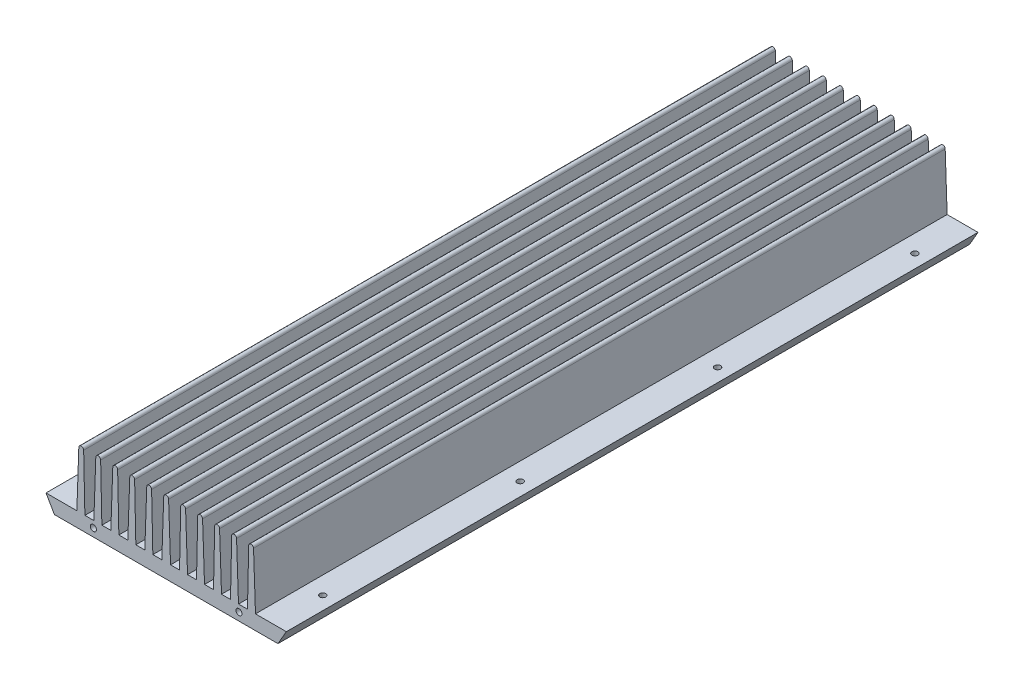
from build123d import *

# Parameters (mm, degrees)
RESSALTO_EXTRUS_O1_DEPTH   = 285
CORTE_EXTRUS_O1_DEPTH      = 309.048697449
CORTE_EXTRUS_O1_DEPTH_BACK = 309.048697449
CORTE_EXTRUS_O2_DEPTH      = 306.556550496
CORTE_EXTRUS_O2_DEPTH_BACK = 306.556550496
ESBO_O3_W                  = 25.376323639
ESBO_O3_H                  = 34.077714497
ESBO_O3_W_2                = 22.64317054
ESBO_O3_H_2                = 30.700240827
ESBO_O4_R                  = 1.25
CORTE_EXTRUS_O3_DEPTH      = 10
ESBO_O5_R                  = 1.25
CORTE_EXTRUS_O4_DEPTH      = 5
ESBO_O7_R                  = 1.65
ESBO_O7_R_2                = 1.25
CORTE_EXTRUS_O5_DEPTH      = 4


with BuildPart() as part:
    # Esboço1 → Ressalto-extrusão1 (new body)
    with BuildSketch(Plane.XY):
        with BuildLine():
            Line((0, 0), (-113, 0))
            Line((-113, 0), (-113, 30))
            Line((-113, 30), (-111, 30))
            Line((-111, 30), (-111, 6))
            Line((-111, 6), (-107.3, 6))
            Line((-107.3, 6), (-106.5, 29))
            ThreePointArc((-106.5, 29), (-105.5, 30), (-104.5, 29))
            Line((-104.5, 29), (-104, 6))
            Line((-104, 6), (-100.3, 6))
            Line((-100.3, 6), (-99.5, 29))
            ThreePointArc((-99.5, 29), (-98.5, 30), (-97.5, 29))
            Line((-97.5, 29), (-97, 6))
            Line((-97, 6), (-93.3, 6))
            Line((-93.3, 6), (-92.5, 29))
            ThreePointArc((-92.5, 29), (-91.5, 30), (-90.5, 29))
            Line((-90.5, 29), (-90, 6))
            Line((-90, 6), (-86.3, 6))
            Line((-86.3, 6), (-85.5, 29))
            ThreePointArc((-85.5, 29), (-84.5, 30), (-83.5, 29))
            Line((-83.5, 29), (-83, 6))
            Line((-83, 6), (-79.3, 6))
            Line((-79.3, 6), (-78.5, 29))
            ThreePointArc((-78.5, 29), (-77.5, 30), (-76.5, 29))
            Line((-76.5, 29), (-76, 6))
            Line((-76, 6), (-72.3, 6))
            Line((-72.3, 6), (-71.5, 29))
            ThreePointArc((-71.5, 29), (-70.5, 30), (-69.5, 29))
            Line((-69.5, 29), (-69, 6))
            Line((-69, 6), (-65.3, 6))
            Line((-65.3, 6), (-64.5, 29))
            ThreePointArc((-64.5, 29), (-63.5, 30), (-62.5, 29))
            Line((-62.5, 29), (-62, 6))
            Line((-62, 6), (-58.3, 6))
            Line((-58.3, 6), (-57.5, 29))
            ThreePointArc((-57.5, 29), (-56.5, 30), (-55.5, 29))
            Line((-55.5, 29), (-54.7, 6))
            Line((-54.7, 6), (-51, 6))
            Line((-51, 6), (-50.5, 29))
            ThreePointArc((-50.5, 29), (-49.5, 30), (-48.5, 29))
            Line((-48.5, 29), (-47.7, 6))
            Line((-47.7, 6), (-44, 6))
            Line((-44, 6), (-43.5, 29))
            ThreePointArc((-43.5, 29), (-42.5, 30), (-41.5, 29))
            Line((-41.5, 29), (-40.7, 6))
            Line((-40.7, 6), (-37, 6))
            Line((-37, 6), (-36.5, 29))
            ThreePointArc((-36.5, 29), (-35.5, 30), (-34.5, 29))
            Line((-34.5, 29), (-33.7, 6))
            Line((-33.7, 6), (-30, 6))
            Line((-30, 6), (-29.5, 29))
            ThreePointArc((-29.5, 29), (-28.5, 30), (-27.5, 29))
            Line((-27.5, 29), (-26.7, 6))
            Line((-26.7, 6), (-23, 6))
            Line((-23, 6), (-22.5, 29))
            ThreePointArc((-22.5, 29), (-21.5, 30), (-20.5, 29))
            Line((-20.5, 29), (-19.7, 6))
            Line((-19.7, 6), (-16, 6))
            Line((-16, 6), (-15.5, 29))
            ThreePointArc((-15.5, 29), (-14.5, 30), (-13.5, 29))
            Line((-13.5, 29), (-12.7, 6))
            Line((-12.7, 6), (-9, 6))
            Line((-9, 6), (-8.5, 29))
            ThreePointArc((-8.5, 29), (-7.5, 30), (-6.5, 29))
            Line((-6.5, 29), (-5.7, 6))
            Line((-5.7, 6), (-2, 6))
            Line((-2, 6), (-2, 30))
            Line((-2, 30), (0, 30))
            Line((0, 30), (0, 0))
        make_face()
    extrude(amount=RESSALTO_EXTRUS_O1_DEPTH)

    # Esboço2 → Corte-extrusão1 (cut, two sides: drawn at the far end of the back side and taken through both)
    with BuildSketch(Plane.XY.offset(285).offset(-CORTE_EXTRUS_O1_DEPTH_BACK)):
        Polygon((-10.446152423, 0), (0, 0), (0, 41.820832928), (-6.982050808, 41.820832928), (-6.982050808, 6), align=None)
        Polygon((-102.553847577, 0), (-103.553847577, 1.732050808), (-106.017949192, 6), (-106.017949192, 31.540588642), (-125.556799279, 31.540588642), (-125.556799279, -3.436706701), (-107.964469124, -3.436706701), align=None)
    extrude(amount=CORTE_EXTRUS_O1_DEPTH + CORTE_EXTRUS_O1_DEPTH_BACK, mode=Mode.SUBTRACT)

    # Esboço3 → Corte-extrusão2 (cut, two sides: drawn at the far end of the back side and taken through both)
    with BuildSketch(Plane.XY.offset(285).offset(-CORTE_EXTRUS_O2_DEPTH_BACK)):
        with Locations((-109.68816182, 23.038857249)):
            Rectangle(ESBO_O3_W, ESBO_O3_H)
        with Locations((-4.67841473, 21.350120414)):
            Rectangle(ESBO_O3_W_2, ESBO_O3_H_2)
    extrude(amount=CORTE_EXTRUS_O2_DEPTH + CORTE_EXTRUS_O2_DEPTH_BACK, mode=Mode.SUBTRACT)

    # Esboço4 → Corte-extrusão3 (cut)
    with BuildSketch(Plane.XY.offset(285)):
        with Locations((-26.5, 3.234792224)):
            Circle(ESBO_O4_R)
        with Locations((-86.5, 3.234792224)):
            Circle(ESBO_O4_R)
    extrude(amount=-CORTE_EXTRUS_O3_DEPTH, mode=Mode.SUBTRACT)

    # Esboço5 → Corte-extrusão4 (cut)
    with BuildSketch(Plane(origin=(0, 6, 0), x_dir=(1, 0, 0), z_dir=(0, 1, 0))):
        with Locations((-99.03293992, -274.5)):
            Circle(ESBO_O5_R)
        with Locations((-99.03293992, -208.5)):
            Circle(ESBO_O5_R)
        with Locations((-99.03293992, -142.5)):
            Circle(ESBO_O5_R)
        with Locations((-99.03293992, -76.5)):
            Circle(ESBO_O5_R)
        with Locations((-99.03293992, -10.5)):
            Circle(ESBO_O5_R)
        with Locations((-12.464550988, -20.5)):
            Circle(ESBO_O5_R)
        with Locations((-12.464550988, -101.833333333)):
            Circle(ESBO_O5_R)
        with Locations((-12.464550988, -183.166666667)):
            Circle(ESBO_O5_R)
        with Locations((-12.464550988, -264.5)):
            Circle(ESBO_O5_R)
    extrude(amount=-CORTE_EXTRUS_O4_DEPTH, mode=Mode.SUBTRACT)

    # Esboço7 → Corte-extrusão5 (cut)
    with BuildSketch(Plane(origin=(0, 0, 0), x_dir=(-1, 0, 0), z_dir=(0, -1, 0))):
        with Locations((95, -28.5)):
            Circle(ESBO_O7_R)
        with Locations((71.949, -28.592)):
            Circle(ESBO_O7_R_2)
        with Locations((72.33, -10.685)):
            Circle(ESBO_O7_R_2)
        with Locations((30.928, -51.5)):
            Circle(ESBO_O7_R_2)
        with Locations((24, -15)):
            Circle(ESBO_O7_R)
        with Locations((34.738, -79.011)):
            Circle(ESBO_O7_R_2)
        with Locations((18.355, -144.416)):
            Circle(ESBO_O7_R)
        with Locations((20, -249)):
            Circle(ESBO_O7_R)
        with Locations((35.246, -237)):
            Circle(ESBO_O7_R_2)
        with Locations((93, -249)):
            Circle(ESBO_O7_R)
        with Locations((78.807, -182.77)):
            Circle(ESBO_O7_R_2)
        with Locations((82.363, -100.093)):
            Circle(ESBO_O7_R_2)
        with Locations((29.404, -176.293)):
            Circle(ESBO_O7_R_2)
        with Locations((38.999998474, -219.999999573)):
            Circle(ESBO_O7_R_2)
        with Locations((38.999998474, -199.999999573)):
            Circle(ESBO_O7_R_2)
        with Locations((38.999998474, -179.999999573)):
            Circle(ESBO_O7_R_2)
        with Locations((38.999998474, -159.999999573)):
            Circle(ESBO_O7_R_2)
        with Locations((73.999998474, -129.999991943)):
            Circle(ESBO_O7_R_2)
        with Locations((73.999998474, -110.000007202)):
            Circle(ESBO_O7_R_2)
        with Locations((73.999998474, -90.000007202)):
            Circle(ESBO_O7_R_2)
        with Locations((73.999998474, -69.999991943)):
            Circle(ESBO_O7_R_2)
    extrude(amount=-CORTE_EXTRUS_O5_DEPTH, mode=Mode.SUBTRACT)


solid = part.part
